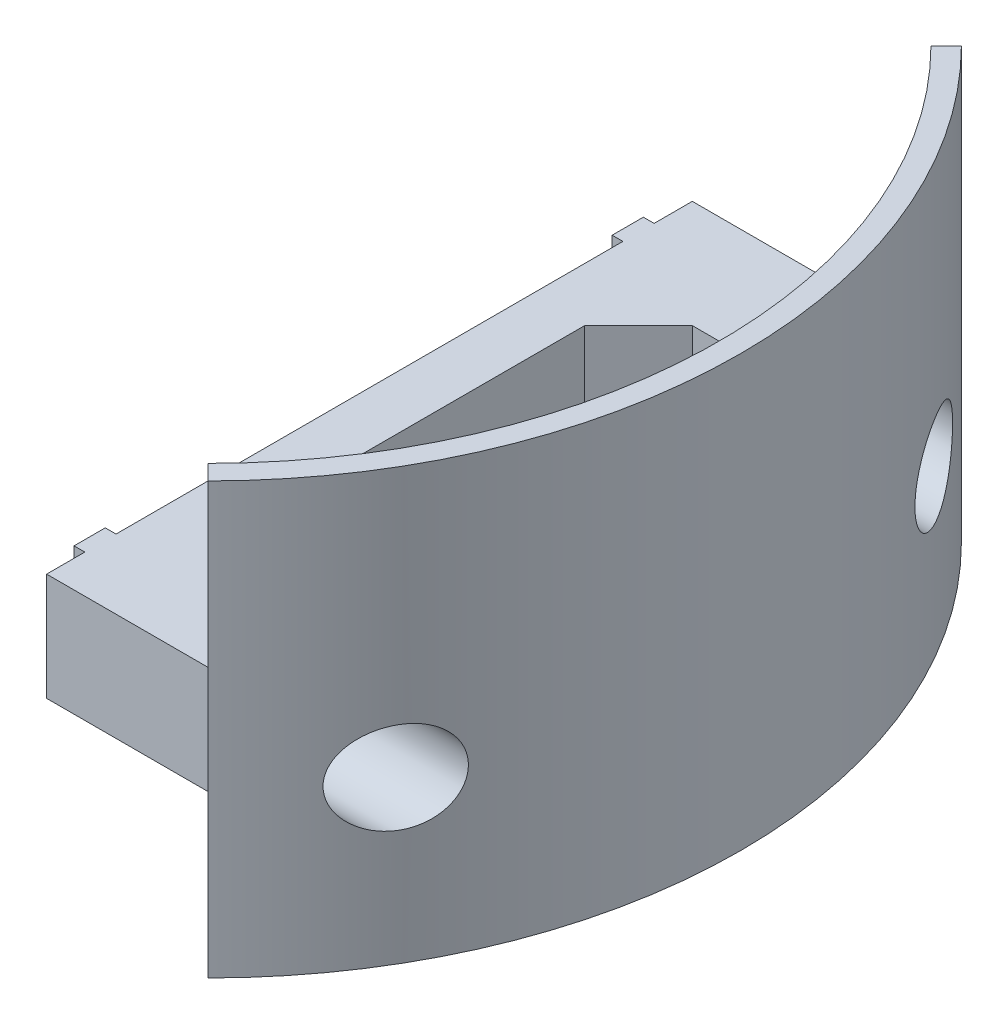
from build123d import *

# Parameters (mm, degrees)
SKETCH1_W           = 2
SKETCH1_H           = 40
MAIN_ANGLE          = 90
SUPPORT_DEPTH       = 10
SKETCH6_W           = 1
SKETCH6_H           = 2.9
FIX_2_DEPTH         = 10
SKETCH9_R           = 1.6
HOLES_DEPTH         = 7
SKETCH10_R          = 4.25
BIGHOLES_DEPTH      = 30.5
BOSS_EXTRUDE3_DEPTH = 10


with BuildPart() as part:
    # Sketch1 → Main (revolve, symmetric)
    with BuildSketch(Plane.XY) as main_sk:
        with Locations((48.5, 20)):
            Rectangle(SKETCH1_W, SKETCH1_H)
    revolve(axis=Axis((0, -0.284703924, 0), (0, 1, 0)), revolution_arc=MAIN_ANGLE / 2)
    revolve(main_sk.sketch, axis=Axis((0, -0.284703924, 0), (0, -1, 0)), revolution_arc=MAIN_ANGLE / 2)

    # Sketch2 → Support (add)
    with BuildSketch(Plane(origin=(0, 10, 0), x_dir=(-1, 0, 0), z_dir=(0, -1, 0))):
        with BuildLine():
            Line((-43.084219849, -20), (-20, -20))
            Line((-20, -20), (-20, 20))
            Line((-20, 20), (-43.084219849, 20))
            ThreePointArc((-43.084219849, 20), (-40.267390497, 25.194984869), (-36.827299657, 30))
            Line((-36.827299657, 30), (-15, 30))
            Line((-15, 30), (-15, -30))
            Line((-15, -30), (-36.827299657, -30))
            ThreePointArc((-36.827299657, -30), (-40.267390497, -25.194984869), (-43.084219849, -20))
        make_face()
    extrude(amount=-SUPPORT_DEPTH)

    # Sketch6 → Fix 2 (add)
    with BuildSketch(Plane(origin=(0, 10, 0), x_dir=(1, 0, 0), z_dir=(0, 1, 0))):
        with Locations((14.5, -25)):
            Rectangle(SKETCH6_W, SKETCH6_H)
        with Locations((14.5, 25)):
            Rectangle(SKETCH6_W, SKETCH6_H)
    extrude(amount=FIX_2_DEPTH)

    # Sketch9 → Holes (cut, through all)
    with BuildSketch(Plane(origin=(20, 0, 0), x_dir=(0, 0, -1), z_dir=(1, 0, 0))):
        with Locations((25, 15)):
            Circle(SKETCH9_R)
        with Locations((-25, 15)):
            Circle(SKETCH9_R)
    extrude(amount=-HOLES_DEPTH, mode=Mode.SUBTRACT)

    # Sketch10 → BigHoles (cut, through all)
    with BuildSketch(Plane(origin=(20, 0, 0), x_dir=(0, 0, -1), z_dir=(1, 0, 0))):
        with Locations((25, 15)):
            Circle(SKETCH10_R)
        with Locations((-25, 15)):
            Circle(SKETCH10_R)
    extrude(amount=BIGHOLES_DEPTH, mode=Mode.SUBTRACT)

    # Sketch11 → Boss-Extrude3 (add)
    with BuildSketch(Plane(origin=(0, 20, 0), x_dir=(1, 0, 0), z_dir=(0, 1, 0))):
        Polygon((20, 20), (25, 20), (20, 15), align=None)
        Polygon((20, -20), (20, -15), (25, -20), align=None)
        Polygon((40.279686395, 20), (45.279686395, 20), (45.279686395, 15), align=None)
        Polygon((40.279686395, -20), (45.279686395, -20), (45.279686395, -14.352700094), align=None)
    extrude(amount=-BOSS_EXTRUDE3_DEPTH)


solid = part.part
